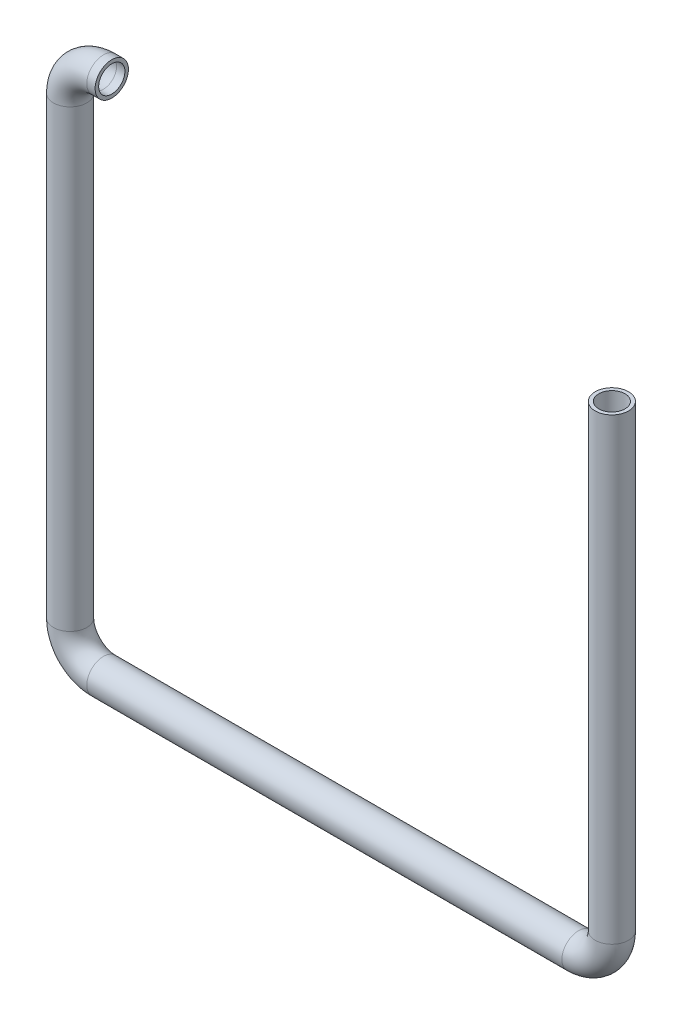
from build123d import *

# Parameters (mm, degrees)
SKETCH2_R   = 4
SKETCH2_R_2 = 3.15


with BuildPart() as part:
    # Sweep1: sweep along a path in Sketch1
    with BuildLine(Plane.XY) as sweep1_path:
        Line((0, 0), (-2, 0))
        ThreePointArc((-2, 0), (-7.656854249, -2.343145751), (-10, -8))
        Line((-10, -8), (-10, -117))
        ThreePointArc((-10, -117), (-7.656854249, -122.656854249), (-2, -125))
        Line((-2, -125), (112, -125))
        ThreePointArc((112, -125), (117.656854249, -122.656854249), (120, -117))
        Line((120, -117), (120, -7))
    # Sketch2 → Sweep1 (sweep)
    with BuildSketch(Plane(origin=(0, 0, 0), x_dir=(0, 0, -1), z_dir=(1, 0, 0))):
        Circle(SKETCH2_R)
        Circle(SKETCH2_R_2, mode=Mode.SUBTRACT)
    sweep(path=sweep1_path.line)


solid = part.part
